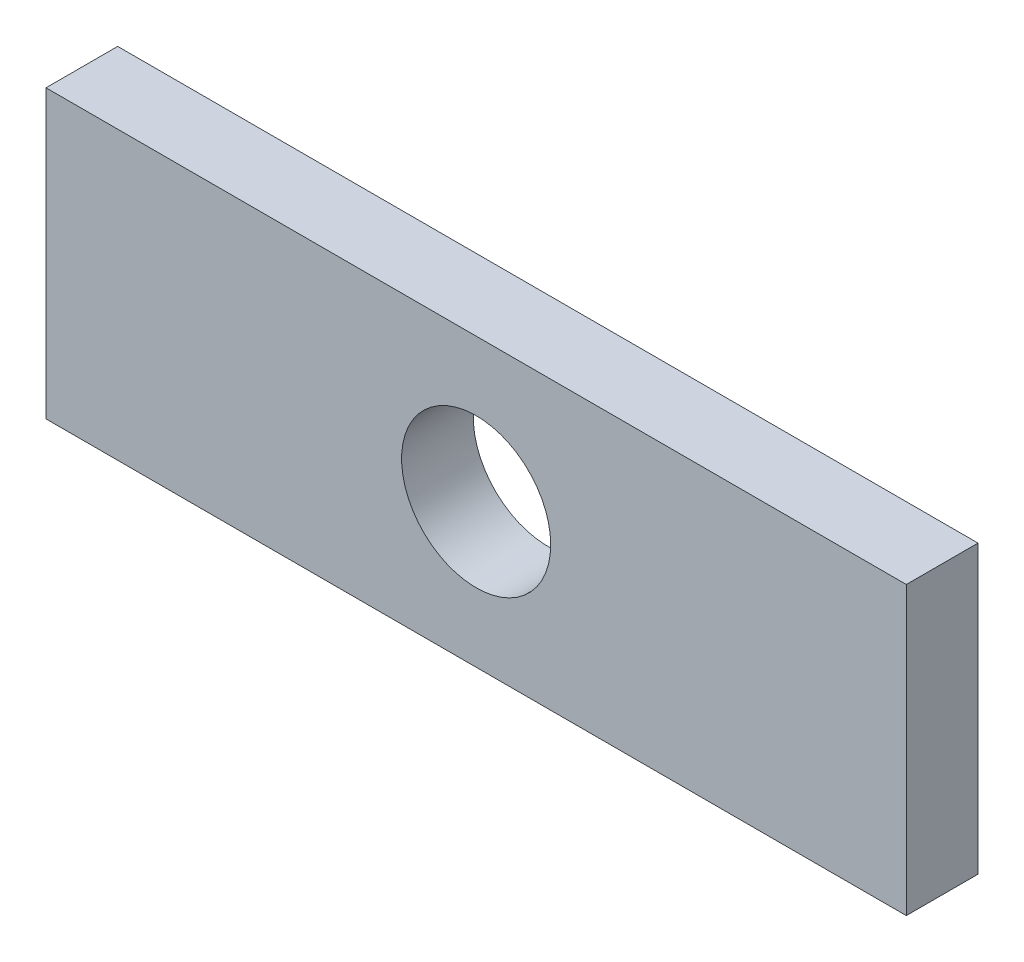
from build123d import *

# Parameters (mm, degrees)
SKETCH1_W      = 38.1
SKETCH1_H      = 12.7
SKETCH1_R      = 3.302
EXTRUDE1_DEPTH = 3.175


with BuildPart() as part:
    # Sketch1 → Extrude1 (new body)
    with BuildSketch(Plane.XY):
        Rectangle(SKETCH1_W, SKETCH1_H)
        Circle(SKETCH1_R, mode=Mode.SUBTRACT)
    extrude(amount=EXTRUDE1_DEPTH)


solid = part.part
